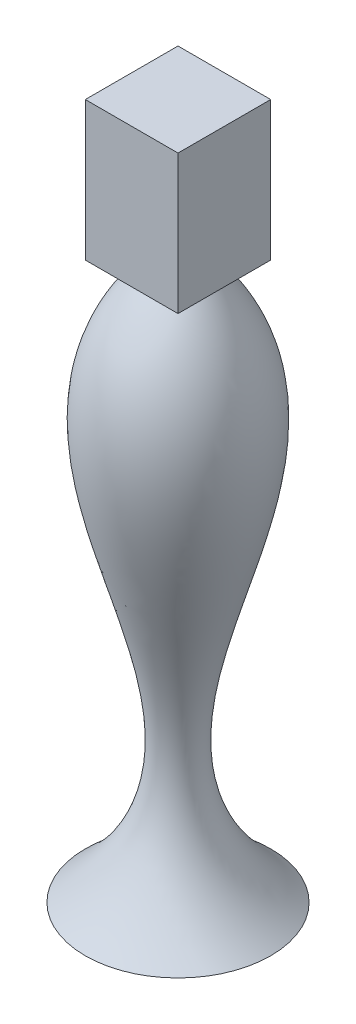
from build123d import *

# Parameters (mm, degrees)
SKETCH10_W          = 101.6
SKETCH10_H          = 101.6
BOSS_EXTRUDE5_DEPTH = 152.4


with BuildPart() as part:
    # Sketch1 → Revolve3 (revolve)
    with BuildSketch(Plane.XY):
        with BuildLine():
            Line((0, 0), (0, -152.4))
            Line((0, -152.4), (-101.6, -152.4))
            add(Edge.make_bspline(
                [(-101.6, -152.4), (112.233734467, 26.074070803), (-211.807575975, 256.743639399), (-25.4, 457.2)],
                knots=[0, 0, 0, 0, 1, 1, 1, 1], degree=3))
            Line((-25.4, 457.2), (0, 457.2))
            Line((0, 457.2), (0, 0))
        make_face()
    revolve(axis=Axis((0, 0, 0), (0, 1, 0)))

    # Sketch10 → Boss-Extrude5 (add)
    with BuildSketch(Plane(origin=(0, 457.2, 0), x_dir=(1, 0, 0), z_dir=(0, 1, 0))):
        Rectangle(SKETCH10_W, SKETCH10_H)
    extrude(amount=BOSS_EXTRUDE5_DEPTH)


solid = part.part
